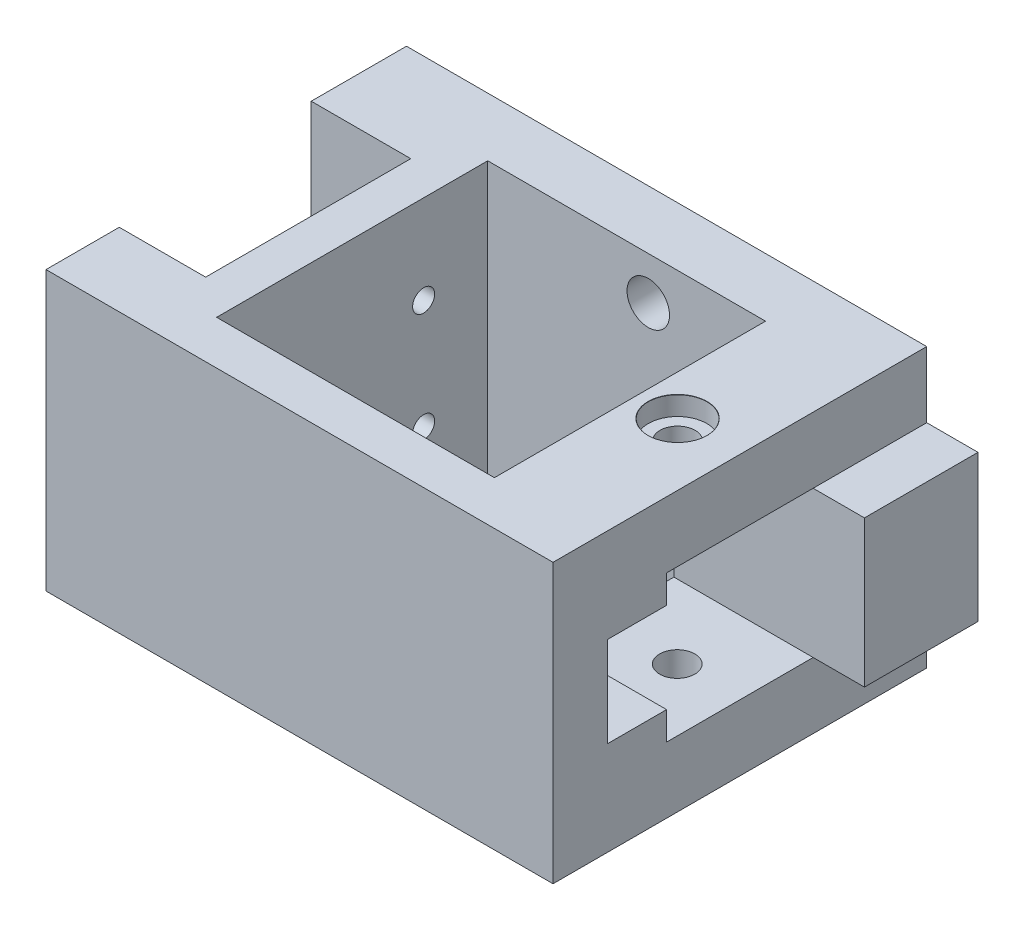
from build123d import *

# Parameters (mm, degrees)
SALIENTE_EXTRUIR1_DEPTH                     = 38
CROQUIS2_W                                  = 32.911764705
CROQUIS2_H                                  = 37
CORTAR_EXTRUIR1_DEPTH                       = 38
CROQUIS3_R                                  = 1.5
CORTAR_EXTRUIR3_DEPTH                       = 10
CROQUIS5_W                                  = 13.588235295
CROQUIS5_H                                  = 38
CORTAR_EXTRUIR4_DEPTH                       = 1
CROQUIS8_W                                  = 20
CROQUIS8_H                                  = 20
CORTAR_EXTRUIR5_DEPTH                       = 8
CROQUIS10_W                                 = 8
CROQUIS10_H                                 = 12
CORTAR_EXTRUIR7_DEPTH                       = 10
CROQUIS11_W                                 = 10
CROQUIS11_H                                 = 38
CORTAR_EXTRUIR8_DEPTH                       = 1.8
CROQUIS13_W                                 = 49
CROQUIS13_H                                 = 38
SALIENTE_EXTRUIR2_DEPTH                     = 12
CROQUIS15_W                                 = 71
CROQUIS15_H                                 = 38
SALIENTE_EXTRUIR3_DEPTH                     = 2
REFRENTADO_PARA_TORNILLO_CON_CABEZA_2_COUNT = 2
REFRENTADO_PARA_TORNILLO_CON_CABEZA_2_PITCH = 26.31900454
CROQUIS18_W                                 = 19
CROQUIS18_H                                 = 8
CORTAR_EXTRUIR9_DEPTH                       = 0.16
CROQUIS19_W                                 = 19
CROQUIS19_H                                 = 8
CORTAR_EXTRUIR10_DEPTH                      = 0.16
CROQUIS20_W                                 = 19
CROQUIS20_H                                 = 12.32
CORTAR_EXTRUIR11_DEPTH                      = 0.1
CHAFL_N3_SIZE                               = 5
CROQUIS26_W                                 = 15.5
CROQUIS26_H                                 = 20
SALIENTE_EXTRUIR4_DEPTH                     = 7


with BuildPart() as part:
    # Croquis1 → Saliente-Extruir1 (new body)
    with BuildSketch(Plane(origin=(0, 0, 0), x_dir=(1, 0, 0), z_dir=(0, 1, 0))):
        Polygon((-121.647058824, 30.882352941), (-62.647058824, 30.882352941), (-62.647058824, -18.117647059), (-121.647058824, -18.117647059), (-121.647058824, -7.117647059), (-108.058823529, -7.117647059), (-108.058823529, 19.882352941), (-121.647058824, 19.882352941), align=None)
    extrude(amount=SALIENTE_EXTRUIR1_DEPTH)

    # Croquis2 → Cortar-Extruir1 (cut)
    with BuildSketch(Plane(origin=(0, 38, 0), x_dir=(1, 0, 0), z_dir=(0, 1, 0))):
        with Locations((-86.102941176, 6.382352941)):
            Rectangle(CROQUIS2_W, CROQUIS2_H)
    extrude(amount=-CORTAR_EXTRUIR1_DEPTH, mode=Mode.SUBTRACT)

    # Croquis3 → Cortar-Extruir3 (cut)
    with BuildSketch(Plane(origin=(-102.558823529, 0, 0), x_dir=(0, 0, -1), z_dir=(1, 0, 0))):
        with Locations((16.132352941, 10.875)):
            Circle(CROQUIS3_R)
        with Locations((16.132352941, 25.875)):
            Circle(CROQUIS3_R)
        with Locations((-3.867647059, 10.875)):
            Circle(CROQUIS3_R)
        with Locations((-3.867647059, 25.875)):
            Circle(CROQUIS3_R)
    extrude(amount=-CORTAR_EXTRUIR3_DEPTH, mode=Mode.SUBTRACT)

    # Croquis5 → Cortar-Extruir4 (cut)
    with BuildSketch(Plane(origin=(0, 0, 7.117647059), x_dir=(-1, 0, 0), z_dir=(0, 0, -1))):
        with Locations((114.852941177, 19)):
            Rectangle(CROQUIS5_W, CROQUIS5_H)
    extrude(amount=-CORTAR_EXTRUIR4_DEPTH, mode=Mode.SUBTRACT)

    # Croquis8 → Cortar-Extruir5 (cut)
    with BuildSketch(Plane(origin=(-62.647058824, 0, 0), x_dir=(0, 0, -1), z_dir=(1, 0, 0))):
        with Locations((7.382352941, 19)):
            Rectangle(CROQUIS8_W, CROQUIS8_H)
    extrude(amount=-CORTAR_EXTRUIR5_DEPTH, mode=Mode.SUBTRACT)

    # Croquis10 → Cortar-Extruir7 (cut)
    with BuildSketch(Plane(origin=(-62.647058824, 0, 0), x_dir=(0, 0, -1), z_dir=(1, 0, 0))):
        with Locations((-6.617647059, 19)):
            Rectangle(CROQUIS10_W, CROQUIS10_H)
    extrude(amount=-CORTAR_EXTRUIR7_DEPTH, mode=Mode.SUBTRACT)

    # Croquis11 → Cortar-Extruir8 (cut)
    with BuildSketch(Plane.ZY.offset(121.647058824)):
        with Locations((13.117647059, 19)):
            Rectangle(CROQUIS11_W, CROQUIS11_H)
    extrude(amount=-CORTAR_EXTRUIR8_DEPTH, mode=Mode.SUBTRACT)

    # Croquis13 → Saliente-Extruir2 (add)
    with BuildSketch(Plane(origin=(-62.647058824, 0, 0), x_dir=(0, 0, -1), z_dir=(1, 0, 0))):
        with Locations((6.382352941, 19)):
            Rectangle(CROQUIS13_W, CROQUIS13_H)
        Polygon((17.382352941, 9), (17.382352941, 29), (-2.617647059, 29), (-2.617647059, 25), (-10.617647059, 25), (-10.617647059, 13), (-2.617647059, 13), (-2.617647059, 9), align=None, mode=Mode.SUBTRACT)
    extrude(amount=SALIENTE_EXTRUIR2_DEPTH)

    # Croquis15 → Saliente-Extruir3 (add)
    with BuildSketch(Plane(origin=(0, 0, -30.882352941), x_dir=(-1, 0, 0), z_dir=(0, 0, -1))):
        with Locations((86.147058824, 19)):
            Rectangle(CROQUIS15_W, CROQUIS15_H)
    extrude(amount=SALIENTE_EXTRUIR3_DEPTH)

    # Croquis17 → Refrentado para tornillo con cabeza plan (revolve, cut)
    with BuildSketch(Plane(origin=(-81.647058824, 5.85, -32.882352941), x_dir=(0, 1, 0), z_dir=(1, 0, 0))):
        Polygon((0, 0), (0, 21.742495795), (2.9, 20), (2.9, 3.3), (5, 3.3), (5, 0.2), (5.2, 0), align=None)
    refrentado_para_tornillo_con_cabeza_plan = revolve(axis=Axis((-81.647058824, 5.85, -39.232352941), (0, 0, 1)), mode=Mode.SUBTRACT)

    # Refrentado para tornillo con cabeza  2: Refrentado para tornillo con cabeza plan ×2
    with Locations(*[Vector(0.037995358, 0.999277916, 0) * (i * REFRENTADO_PARA_TORNILLO_CON_CABEZA_2_PITCH) for i in range(1, REFRENTADO_PARA_TORNILLO_CON_CABEZA_2_COUNT)]):
        add(refrentado_para_tornillo_con_cabeza_plan, mode=Mode.SUBTRACT)

    # Croquis18 → Cortar-Extruir9 (cut)
    with BuildSketch(Plane(origin=(0, 13, 0), x_dir=(1, 0, 0), z_dir=(0, 1, 0))):
        with Locations((-60.147058824, -6.617647059)):
            Rectangle(CROQUIS18_W, CROQUIS18_H)
    extrude(amount=-CORTAR_EXTRUIR9_DEPTH, mode=Mode.SUBTRACT)

    # Croquis19 → Cortar-Extruir10 (cut)
    with BuildSketch(Plane(origin=(0, 25, 0), x_dir=(-1, 0, 0), z_dir=(0, -1, 0))):
        with Locations((60.147058824, -6.617647059)):
            Rectangle(CROQUIS19_W, CROQUIS19_H)
    extrude(amount=-CORTAR_EXTRUIR10_DEPTH, mode=Mode.SUBTRACT)

    # Croquis20 → Cortar-Extruir11 (cut)
    with BuildSketch(Plane(origin=(0, 0, 10.617647059), x_dir=(-1, 0, 0), z_dir=(0, 0, -1))):
        with Locations((60.147058824, 19)):
            Rectangle(CROQUIS20_W, CROQUIS20_H)
    extrude(amount=-CORTAR_EXTRUIR11_DEPTH, mode=Mode.SUBTRACT)

    # Croquis23 → Refrentado para tornillo con cabeza  3 (revolve, cut)
    with BuildSketch(Plane(origin=(-59.147058824, 0, -7.332227312), x_dir=(0, 0, -1), z_dir=(1, 0, 0))):
        Polygon((0, 0), (0, 21.442065486), (2.4, 20), (2.4, 2.6), (4, 2.6), (4, 0.025), (4.025, 0), align=None)
    revolve(axis=Axis((-59.147058824, -6.35, -7.332227312), (0, 1, 0)), mode=Mode.SUBTRACT)

    # Croquis25 → Refrentado para tornillo con cabeza  4 (revolve, cut)
    with BuildSketch(Plane(origin=(-59.147058824, 38, -7.382352941), x_dir=(0, 0, 1), z_dir=(1, 0, 0))):
        Polygon((0, 0), (0, 21.442065486), (2.4, 20), (2.4, 2.6), (4, 2.6), (4, 0.025), (4.025, 0), align=None)
    revolve(axis=Axis((-59.147058824, 44.35, -7.382352941), (0, -1, 0)), mode=Mode.SUBTRACT)

    # Chaflán3
    chafl_n3_edges = [part.edges().sort_by_distance(p)[0] for p in [
        (-69.647058824, 0, -6.382352941),
        (-69.647058824, 38, -6.382352941),
    ]]
    chamfer(chafl_n3_edges, length=CHAFL_N3_SIZE)

    # Croquis26 → Saliente-Extruir4 (add)
    with BuildSketch(Plane(origin=(-50.647058824, 0, 0), x_dir=(0, 0, -1), z_dir=(1, 0, 0))):
        with Locations((25.132352941, 19)):
            Rectangle(CROQUIS26_W, CROQUIS26_H)
    extrude(amount=SALIENTE_EXTRUIR4_DEPTH)


solid = part.part
